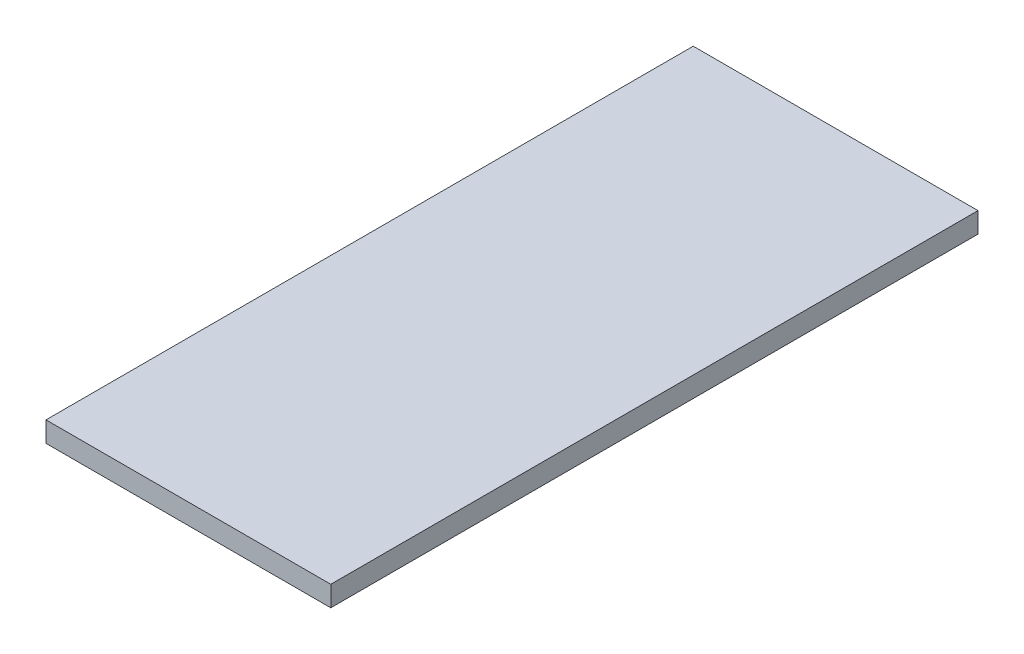
from build123d import *

# Parameters (mm, degrees)
SKETCH1_W           = 22.352
SKETCH1_H           = 50.8
BOSS_EXTRUDE1_DEPTH = 0.8001


with BuildPart() as part:
    # Sketch1 → Boss-Extrude1 (new body, symmetric)
    with BuildSketch(Plane(origin=(0, 0, 0), x_dir=(1, 0, 0), z_dir=(0, 1, 0))):
        Rectangle(SKETCH1_W, SKETCH1_H)
    extrude(amount=BOSS_EXTRUDE1_DEPTH, both=True)


solid = part.part
